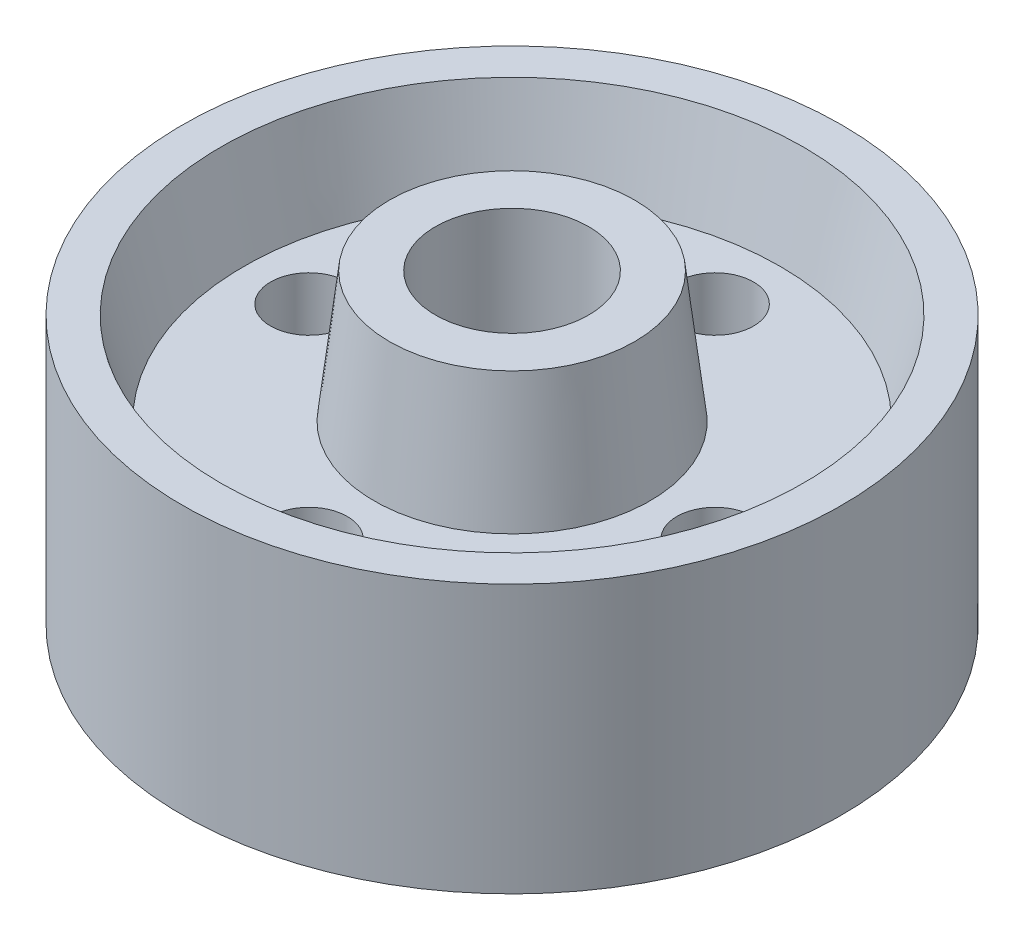
from build123d import *

# Parameters (mm, degrees)
SKETCH2_R          = 10
CUT_EXTRUDE1_DEPTH = 46
SKETCH3_R          = 5
CUT_EXTRUDE2_DEPTH = 29


with BuildPart() as part:
    # Sketch1 → Revolve1 (revolve)
    with BuildSketch(Plane(origin=(0, 0, 0), x_dir=(0, 1, 0), z_dir=(0, 0, 1))):
        Polygon((0, 0), (35, 0), (40, 0), (40, 16), (23, 18), (23, 35), (35, 38), (35, 43), (0, 43), (0, 38), (12, 35), (12, 18), (-5, 16), (-5, 0), align=None)
    revolve(axis=Axis((0, 0, 0), (0, 1, 0)))

    # Sketch2 → Cut-Extrude1 (cut, through all)
    with BuildSketch(Plane.XZ.offset(5)):
        Circle(SKETCH2_R)
    extrude(amount=-CUT_EXTRUDE1_DEPTH, mode=Mode.SUBTRACT)

    # Sketch3 → Cut-Extrude2 (cut, through all)
    with BuildSketch(Plane(origin=(0, 23, 0), x_dir=(-1, 0, 0), z_dir=(0, 1, 0))):
        with Locations((0, 26.5)):
            Circle(SKETCH3_R)
        with Locations((26.5, 0)):
            Circle(SKETCH3_R)
        with Locations((0, -26.5)):
            Circle(SKETCH3_R)
        with Locations((-26.5, 0)):
            Circle(SKETCH3_R)
    extrude(amount=-CUT_EXTRUDE2_DEPTH, mode=Mode.SUBTRACT)


solid = part.part
